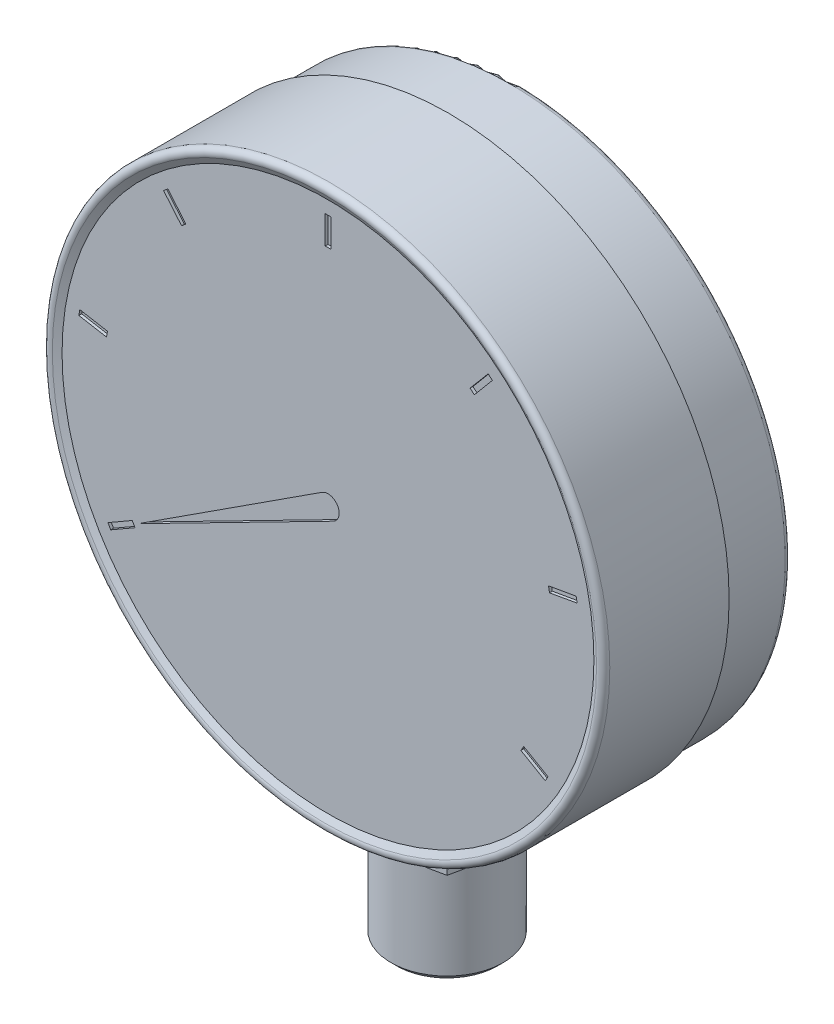
from build123d import *

# Parameters (mm, degrees)
ZAOBLIT1_R               = 1
SKICA2_W                 = 1
SKICA2_H                 = 5
ODEBRAT_VYSUNUT_M1_DEPTH = 0.5
KRUHOV_POLE1_COUNT       = 9
ODEBRAT_VYSUNUT_M2_DEPTH = 0.5
SKICA4_W                 = 22
SKICA4_H                 = 22
P_IDAT_VYSUNUT_M1_DEPTH  = 80
ZKOSEN_1_SIZE            = 1


with BuildPart() as part:
    # Skica1 → Rotovat1 (revolve)
    with BuildSketch(Plane(origin=(0, 0, 0), x_dir=(0, 0, -1), z_dir=(1, 0, 0)), mode=Mode.PRIVATE) as rotovat1_sk:
        Polygon((0, 50), (1.5, 47.401923789), (1.5, 0), (35, 0), (35, 49), (23, 49), (23, 50), align=None)
    revolve(rotovat1_sk.sketch.rotate(Axis((0, 0, 0), (0, 0, 1)), 90), axis=Axis((0, 0, 0), (0, 0, 1)))  # turned: the seam where the file's is

    # Zaoblit1
    zaoblit1_edges = [part.edges().sort_by_distance(p)[0] for p in [
        (50, 0, 0),
        (49, 0, -35),
    ]]
    fillet(zaoblit1_edges, radius=ZAOBLIT1_R)

    # Skica2 → Odebrat vysunutím1 (cut)
    with BuildSketch(Plane.XY.offset(-1.5)):
        with Locations((0, 42.5)):
            Rectangle(SKICA2_W, SKICA2_H)
    odebrat_vysunut_m1 = extrude(amount=-ODEBRAT_VYSUNUT_M1_DEPTH, mode=Mode.SUBTRACT)

    # Kruhové pole1: Odebrat vysunutím1 ×9 about axis, 2 skipped
    kruhov_pole1_axis = Axis((0, 0, 0), (0, 0, -1))
    add([odebrat_vysunut_m1.rotate(kruhov_pole1_axis, i * 360 / KRUHOV_POLE1_COUNT) for i in range(1, KRUHOV_POLE1_COUNT) if i not in (4, 5)], mode=Mode.SUBTRACT)

    # Skica3 → Odebrat vysunutím2 (cut)
    with BuildSketch(Plane.XY.offset(-1.5)):
        with BuildLine():
            Line((-1.087507328, 1.678489741), (-33.774990748, -19.5))
            Line((-33.774990748, -19.5), (0.909861092, -1.781053844))
            ThreePointArc((0.909861092, -1.781053844), (1.732050808, 1), (-1.087507328, 1.678489741))
        make_face()
    extrude(amount=-ODEBRAT_VYSUNUT_M2_DEPTH, mode=Mode.SUBTRACT)

    # Skica4 → Přidat vysunutím1 (add)
    with BuildSketch(Plane(origin=(0, 0, 0), x_dir=(1, 0, 0), z_dir=(0, 1, 0))):
        with Locations((0, 22.732050808)):
            Rectangle(SKICA4_W, SKICA4_H)
    extrude(amount=-P_IDAT_VYSUNUT_M1_DEPTH)

    # Skica5 → Odebrat rotací1 (revolve, cut)
    with BuildSketch(Plane(origin=(0, 0, 0), x_dir=(0, 0, -1), z_dir=(1, 0, 0)), mode=Mode.PRIVATE) as odebrat_rotac_1_sk:
        Polygon((-8.267949192, -52.373066959), (12.732050808, -58), (12.732050808, -77), (19.732050808, -77), (19.732050808, -80), (-8.267949192, -80), align=None)
    revolve(odebrat_rotac_1_sk.sketch.rotate(Axis((0, -80, -22.732050808), (0, 1, 0)), 180), axis=Axis((0, -80, -22.732050808), (0, 1, 0)), mode=Mode.SUBTRACT)  # turned: the seam where the file's is

    # Zkosení1
    zkosen_1_edges = [part.edges().sort_by_distance(p)[0] for p in [
        (0, -77, -12.732050808),
    ]]
    chamfer(zkosen_1_edges, length=ZKOSEN_1_SIZE)


solid = part.part
